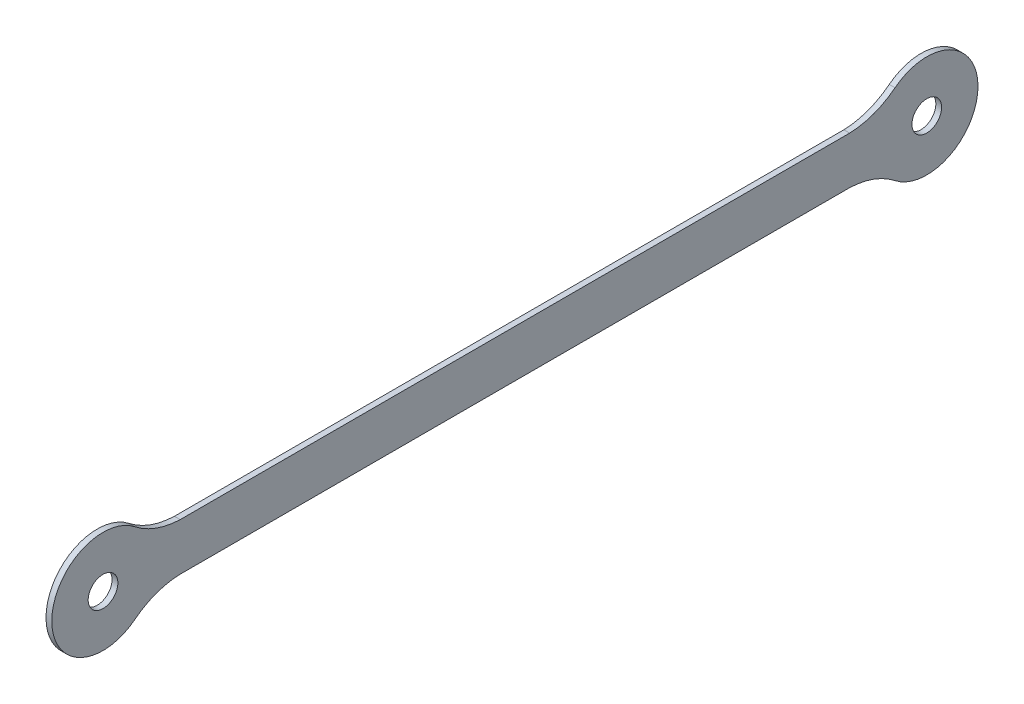
from build123d import *

# Parameters (mm, degrees)
SKETCH_2_R      = 3.85
EXTRUDE_1_DEPTH = 1.5


with BuildPart() as part:
    # 草圖2 → 填料-伸長1 (new body)
    with BuildSketch(Plane(origin=(0, 0, 0), x_dir=(0, 0, -1), z_dir=(1, 0, 0))):
        with BuildLine():
            Line((86.867278103, 6.136277943), (-86.867278103, 6.136277943))
            ThreePointArc((-86.867278103, 6.136277943), (-93.10532064, 7.340711326), (-98.653191396, 10.436670715))
            ThreePointArc((-98.653191396, 10.436670715), (-120.185454546, 0), (-98.653191396, -10.436670715))
            ThreePointArc((-98.653191396, -10.436670715), (-93.10532064, -7.340711326), (-86.867278103, -6.136277943))
            Line((-86.867278103, -6.136277943), (86.867278103, -6.136277943))
            ThreePointArc((86.867278103, -6.136277943), (93.10532064, -7.340711326), (98.653191396, -10.436670715))
            ThreePointArc((98.653191396, -10.436670715), (120.185454546, 0), (98.653191396, 10.436670715))
            ThreePointArc((98.653191396, 10.436670715), (93.10532064, 7.340711326), (86.867278103, 6.136277943))
        make_face()
        with Locations((-106.89, 0)):
            Circle(SKETCH_2_R, mode=Mode.SUBTRACT)
        with Locations((106.89, 0)):
            Circle(SKETCH_2_R, mode=Mode.SUBTRACT)
    extrude(amount=EXTRUDE_1_DEPTH)


solid = part.part
